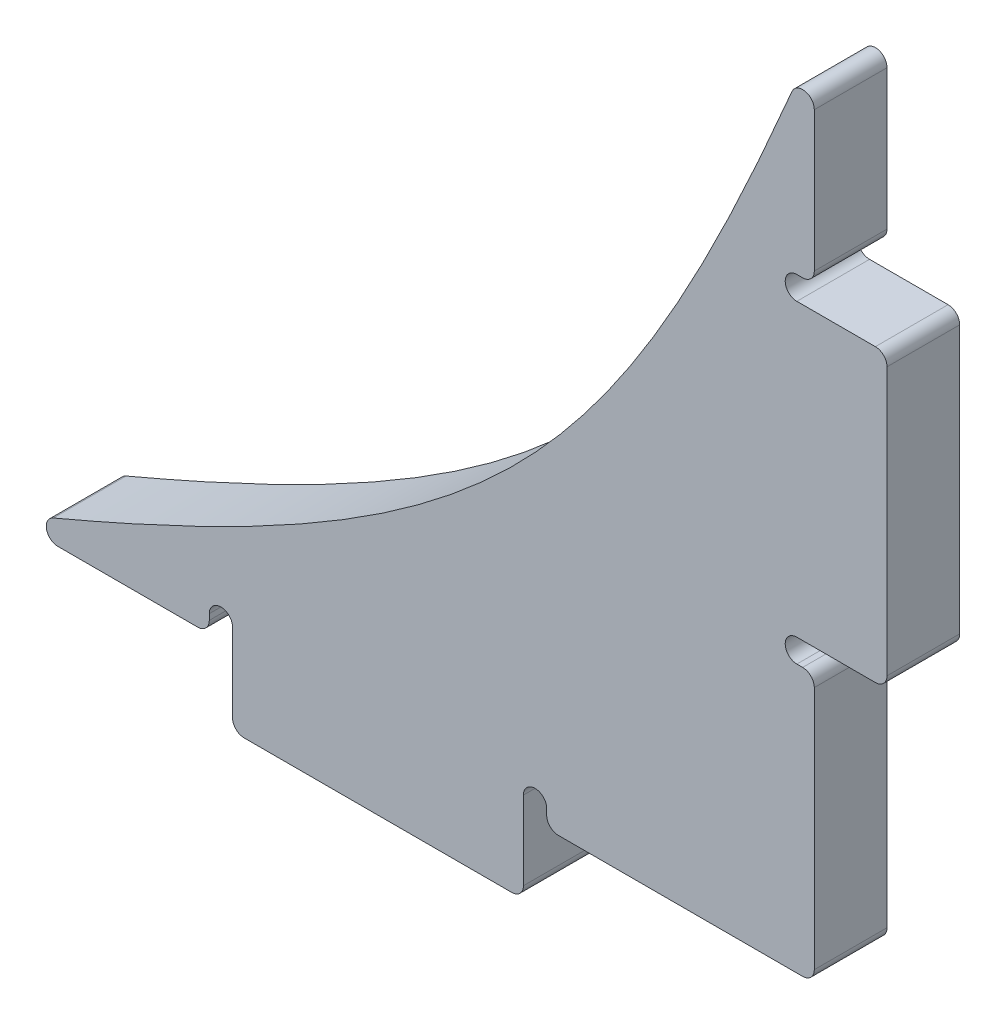
from build123d import *

# Parameters (mm, degrees)
BOSS_EXTRUDE1_DEPTH = 3.175
SKETCH2_W           = 12.7
SKETCH2_H           = 3.175
BOSS_EXTRUDE2_DEPTH = 3.175
SKETCH3_W           = 3.175
SKETCH3_H           = 12.7
BOSS_EXTRUDE3_DEPTH = 3.175
CUT_EXTRUDE1_REACH  = 5.175
FILLET1_R           = 0.508


with BuildPart() as part:
    # Sketch1 → Boss-Extrude1 (new body)
    with BuildSketch(Plane.XY):
        with BuildLine():
            Line((22.86, -12.7), (-12.7, -12.7))
            add(Edge.make_bspline(
                [(22.86, 22.86), (14.060256121, 1.487897552), (8.672102448, -3.900256121), (-12.7, -12.7)],
                knots=[0, 0, 0, 0, 1, 1, 1, 1], degree=3))
            Line((22.86, 22.86), (22.86, -12.7))
        make_face()
    extrude(amount=BOSS_EXTRUDE1_DEPTH)

    # Sketch2 → Boss-Extrude2 (add)
    with BuildSketch(Plane.XZ.offset(12.7)):
        with Locations((3.81, 1.5875)):
            Rectangle(SKETCH2_W, SKETCH2_H)
    extrude(amount=BOSS_EXTRUDE2_DEPTH)

    # Sketch3 → Boss-Extrude3 (add)
    with BuildSketch(Plane(origin=(22.86, 0, 0), x_dir=(0, 0, -1), z_dir=(1, 0, 0))):
        with Locations((-1.5875, 6.35)):
            Rectangle(SKETCH3_W, SKETCH3_H)
    extrude(amount=BOSS_EXTRUDE3_DEPTH)

    # Sketch4 → Cut-Extrude1 (cut, up to next)
    with BuildSketch(Plane.XY.offset(3.175), mode=Mode.PRIVATE) as cut_extrude1_sk1:
        with BuildLine():
            Line((-3.556, -11.938), (-3.556, -12.7))
            Line((-3.556, -12.7), (-2.54, -12.7))
            Line((-2.54, -12.7), (-2.54, -11.938))
            ThreePointArc((-2.54, -11.938), (-3.048, -11.43), (-3.556, -11.938))
        make_face()
    cut_extrude1_tool1 = extrude(cut_extrude1_sk1.sketch, amount=-CUT_EXTRUDE1_REACH, mode=Mode.PRIVATE) & part.part
    add(cut_extrude1_tool1.solids().sort_by_distance((-3.048, -12.113972, 3.175))[0], mode=Mode.SUBTRACT)
    # Sketch4 → Cut-Extrude1 (cut, up to next)
    with BuildSketch(Plane.XY.offset(3.175), mode=Mode.PRIVATE) as cut_extrude1_sk2:
        with BuildLine():
            Line((10.16, -11.938), (10.16, -12.7))
            Line((10.16, -12.7), (11.176, -12.7))
            Line((11.176, -12.7), (11.176, -11.938))
            ThreePointArc((11.176, -11.938), (10.668, -11.43), (10.16, -11.938))
        make_face()
    cut_extrude1_tool2 = extrude(cut_extrude1_sk2.sketch, amount=-CUT_EXTRUDE1_REACH, mode=Mode.PRIVATE) & part.part
    add(cut_extrude1_tool2.solids().sort_by_distance((10.668, -12.113972, 3.175))[0], mode=Mode.SUBTRACT)
    # Sketch4 → Cut-Extrude1 (cut, up to next)
    with BuildSketch(Plane.XY.offset(3.175), mode=Mode.PRIVATE) as cut_extrude1_sk3:
        with BuildLine():
            Line((22.098, -1.016), (22.86, -1.016))
            Line((22.86, -1.016), (22.86, 0))
            Line((22.86, 0), (22.098, 0))
            ThreePointArc((22.098, 0), (21.59, -0.508), (22.098, -1.016))
        make_face()
    cut_extrude1_tool3 = extrude(cut_extrude1_sk3.sketch, amount=-CUT_EXTRUDE1_REACH, mode=Mode.PRIVATE) & part.part
    add(cut_extrude1_tool3.solids().sort_by_distance((22.273972, -0.508, 3.175))[0], mode=Mode.SUBTRACT)
    # Sketch4 → Cut-Extrude1 (cut, up to next)
    with BuildSketch(Plane.XY.offset(3.175), mode=Mode.PRIVATE) as cut_extrude1_sk4:
        with BuildLine():
            Line((22.098, 12.7), (22.86, 12.7))
            Line((22.86, 12.7), (22.86, 13.716))
            Line((22.86, 13.716), (22.098, 13.716))
            ThreePointArc((22.098, 13.716), (21.59, 13.208), (22.098, 12.7))
        make_face()
    cut_extrude1_tool4 = extrude(cut_extrude1_sk4.sketch, amount=-CUT_EXTRUDE1_REACH, mode=Mode.PRIVATE) & part.part
    add(cut_extrude1_tool4.solids().sort_by_distance((22.273972, 13.208, 3.175))[0], mode=Mode.SUBTRACT)

    # Fillet1
    fillet1_edges = [part.edges().sort_by_distance(p)[0] for p in [
        (22.86, 13.716, 1.5875),
        (26.035, 12.7, 1.5875),
        (26.035, 0, 1.5875),
        (22.86, -1.016, 1.5875),
        (22.86, -12.7, 1.5875),
        (11.176, -12.7, 1.5875),
        (10.16, -15.875, 1.5875),
        (-2.54, -15.875, 1.5875),
        (-3.556, -12.7, 1.5875),
        (-12.7, -12.7, 1.5875),
        (22.86, 22.86, 1.5875),
    ]]
    fillet(fillet1_edges, radius=FILLET1_R)


solid = part.part
